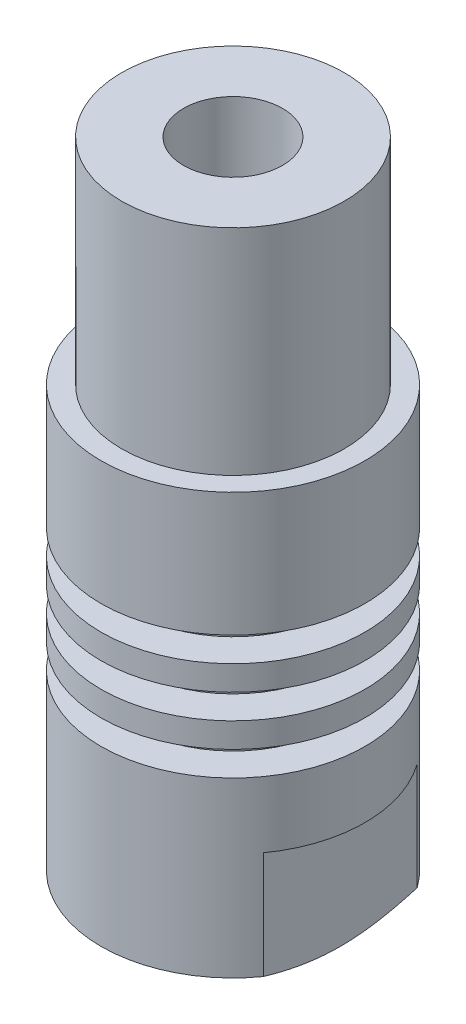
from build123d import *

# Parameters (mm, degrees)
TAGLIO_ESTRUSIONE1_REACH             = 10
SCHIZZO2_W                           = 1.5
SCHIZZO2_H                           = 8
TAGLIO_ESTRUSIONE1_DIRECTION_2_REACH = 10
SCHIZZO7_R                           = 3
TAGLIO_ESTRUSIONE2_DEPTH             = 41
FORO_FILETTATO_M8_1_D                = 6.8
FORO_FILETTATO_M8_1_DEPTH            = 12
FORO_FILETTATO_M8_1_TIP              = 2.042926105
SCHIZZO10_OUTSIDE_W                  = 27.192
SCHIZZO10_OUTSIDE_H                  = 27.192
SCHIZZO10_OUTSIDE_R                  = 6.75
TAGLIO_ESTRUSIONE3_DEPTH             = 13


with BuildPart() as part:
    # Schizzo1 → Rivoluzione1 (revolve)
    with BuildSketch(Plane.XY):
        Polygon((0, 0), (-5, 0), (-8, 1.5), (-8, 12), (-6, 12), (-6, 13.5), (-8, 13.5), (-8, 15), (-6, 15), (-6, 16.5), (-8, 16.5), (-8, 18), (-6, 18), (-6, 19.5), (-8, 19.5), (-8, 27), (-8, 40), (0, 40), align=None)
    revolve(axis=Axis((0, 129.407380346, 0), (0, -1, 0)))

    # Schizzo2 → Taglio-Estrusione1 (cut, up to next)
    with BuildSketch(Plane.XY, mode=Mode.PRIVATE) as taglio_estrusione1_sk1:
        with Locations((-7.25, 4)):
            Rectangle(SCHIZZO2_W, SCHIZZO2_H)
    taglio_estrusione1_tool1 = extrude(taglio_estrusione1_sk1.sketch, amount=-TAGLIO_ESTRUSIONE1_REACH, mode=Mode.PRIVATE) & part.part
    add(taglio_estrusione1_tool1.solids().sort_by_distance((-7.25, 4, 0))[0], mode=Mode.SUBTRACT)
    # Schizzo2 → Taglio-Estrusione1 (cut, up to next)
    with BuildSketch(Plane.XY, mode=Mode.PRIVATE) as taglio_estrusione1_sk2:
        with Locations((7.25, 4)):
            Rectangle(SCHIZZO2_W, SCHIZZO2_H)
    taglio_estrusione1_tool2 = extrude(taglio_estrusione1_sk2.sketch, amount=-TAGLIO_ESTRUSIONE1_REACH, mode=Mode.PRIVATE) & part.part
    add(taglio_estrusione1_tool2.solids().sort_by_distance((7.25, 4, 0))[0], mode=Mode.SUBTRACT)

    # Schizzo2 → Taglio-Estrusione1 direction 2 (cut, up to next)
    with BuildSketch(Plane.XY, mode=Mode.PRIVATE) as taglio_estrusione1_direction_2_sk1:
        with Locations((-7.25, 4)):
            Rectangle(SCHIZZO2_W, SCHIZZO2_H)
    taglio_estrusione1_direction_2_tool1 = extrude(taglio_estrusione1_direction_2_sk1.sketch, amount=TAGLIO_ESTRUSIONE1_DIRECTION_2_REACH, mode=Mode.PRIVATE) & part.part
    add(taglio_estrusione1_direction_2_tool1.solids().sort_by_distance((-7.25, 4, 0))[0], mode=Mode.SUBTRACT)
    # Schizzo2 → Taglio-Estrusione1 direction 2 (cut, up to next)
    with BuildSketch(Plane.XY, mode=Mode.PRIVATE) as taglio_estrusione1_direction_2_sk2:
        with Locations((7.25, 4)):
            Rectangle(SCHIZZO2_W, SCHIZZO2_H)
    taglio_estrusione1_direction_2_tool2 = extrude(taglio_estrusione1_direction_2_sk2.sketch, amount=TAGLIO_ESTRUSIONE1_DIRECTION_2_REACH, mode=Mode.PRIVATE) & part.part
    add(taglio_estrusione1_direction_2_tool2.solids().sort_by_distance((7.25, 4, 0))[0], mode=Mode.SUBTRACT)

    # Schizzo7 → Taglio-Estrusione2 (cut, through all)
    with BuildSketch(Plane(origin=(0, 40, 0), x_dir=(1, 0, 0), z_dir=(0, 1, 0))):
        Circle(SCHIZZO7_R)
    extrude(amount=-TAGLIO_ESTRUSIONE2_DEPTH, mode=Mode.SUBTRACT)

    # Foro filettato M8-1
    with Locations(Plane(origin=(0, 0, 0), x_dir=(-1, 0, 0), z_dir=(0, -1, 0))):
        with Locations((0, 0)):
            Hole(FORO_FILETTATO_M8_1_D / 2, depth=FORO_FILETTATO_M8_1_DEPTH)
            with Locations((0, 0, -(FORO_FILETTATO_M8_1_DEPTH + FORO_FILETTATO_M8_1_TIP / 2))):  # 118° drill point
                Cone(0, FORO_FILETTATO_M8_1_D / 2, FORO_FILETTATO_M8_1_TIP, mode=Mode.SUBTRACT)

    # Schizzo10 outside → Taglio-Estrusione3 (cut)
    with BuildSketch(Plane(origin=(0, 40, 0), x_dir=(1, 0, 0), z_dir=(0, 1, 0))):
        Rectangle(SCHIZZO10_OUTSIDE_W, SCHIZZO10_OUTSIDE_H)
        Circle(SCHIZZO10_OUTSIDE_R, mode=Mode.SUBTRACT)
    extrude(amount=-TAGLIO_ESTRUSIONE3_DEPTH, mode=Mode.SUBTRACT)


solid = part.part
